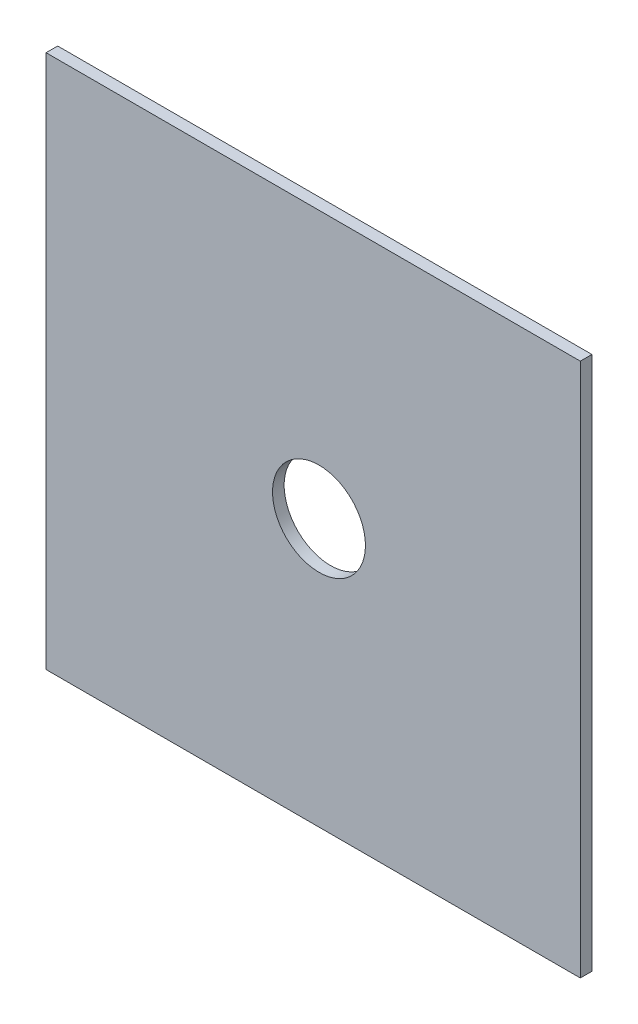
from build123d import *

# Parameters (mm, degrees)
SKETCH1_W           = 146.05
SKETCH1_H           = 146.05
BOSS_EXTRUDE1_DEPTH = 3.175
CUT_EXTRUDE1_DEPTH  = 4.175


with BuildPart() as part:
    # Sketch1 → Boss-Extrude1 (new body)
    with BuildSketch(Plane.XY):
        with Locations((-1.5875, 69.85)):
            Rectangle(SKETCH1_W, SKETCH1_H)
    extrude(amount=BOSS_EXTRUDE1_DEPTH)

    # Sketch2 → Cut-Extrude1 (cut, through all)
    with BuildSketch(Plane.XY.offset(3.175)):
        with BuildLine():
            ThreePointArc((12.7, 69.85), (0, 82.55), (-12.7, 69.85))
            Line((-12.7, 69.85), (0, 69.85))
            Line((0, 69.85), (0, 57.15))
            ThreePointArc((0, 57.15), (8.980256121, 60.869743879), (12.7, 69.85))
        make_face()
        with BuildLine():
            Line((0, 69.85), (-12.7, 69.85))
            ThreePointArc((-12.7, 69.85), (-8.980256121, 60.869743879), (0, 57.15))
            Line((0, 57.15), (0, 69.85))
        make_face()
    extrude(amount=-CUT_EXTRUDE1_DEPTH, mode=Mode.SUBTRACT)


solid = part.part
